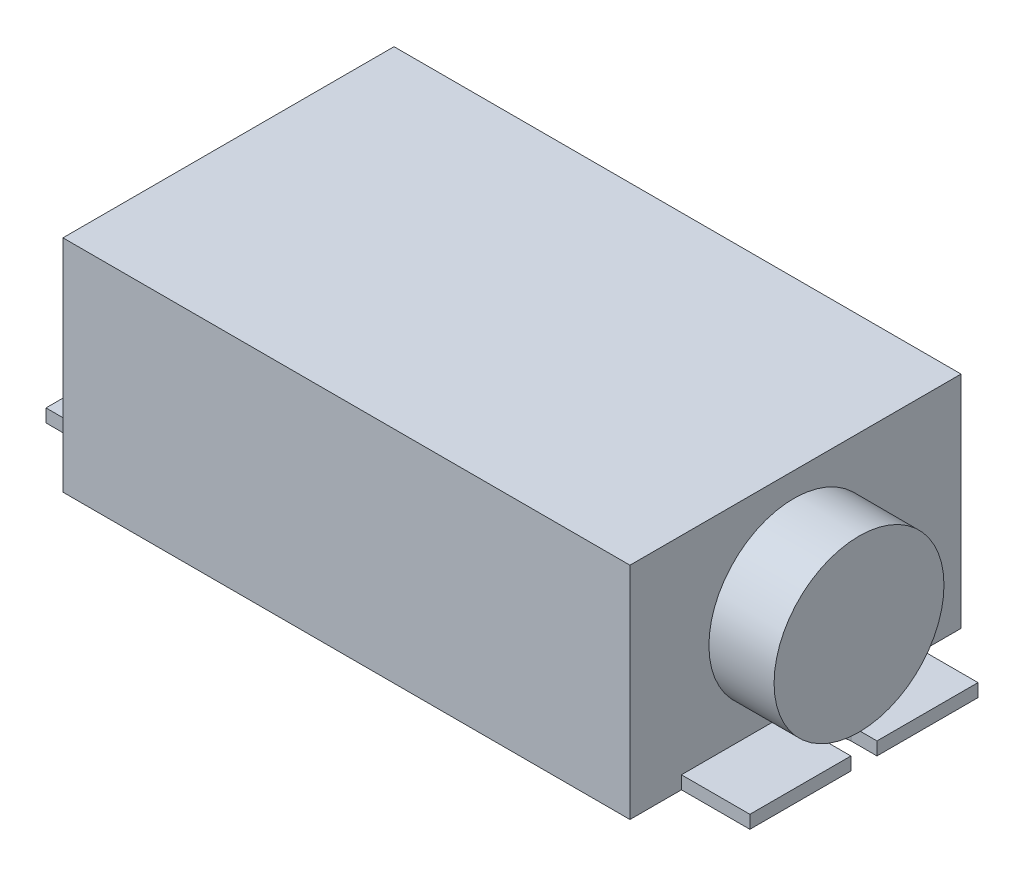
from build123d import *

# Parameters (mm, degrees)
SKETCH1_W           = 87
SKETCH1_H           = 50.8
BOSS_EXTRUDE1_DEPTH = 33.8
BOSS_EXTRUDE2_DEPTH = 2
SKETCH5_R           = 13.034233904
BOSS_EXTRUDE4_DEPTH = 10


with BuildPart() as part:
    # Sketch1 → Boss-Extrude1 (new body)
    with BuildSketch(Plane(origin=(0, 0, 0), x_dir=(1, 0, 0), z_dir=(0, 1, 0))):
        with Locations((43.5, 25.4)):
            Rectangle(SKETCH1_W, SKETCH1_H)
    extrude(amount=BOSS_EXTRUDE1_DEPTH)

    # Sketch2 → Boss-Extrude2 (add)
    with BuildSketch(Plane.XZ):
        with BuildLine():
            Line((0, -42.9), (-10.5, -42.9))
            Line((-10.5, -42.9), (-10.5, -27.4))
            Line((-10.5, -27.4), (-6.5, -27.4))
            ThreePointArc((-6.5, -27.4), (-4.5, -25.4), (-6.5, -23.4))
            Line((-6.5, -23.4), (-10.5, -23.4))
            Line((-10.5, -23.4), (-10.5, -7.9))
            Line((-10.5, -7.9), (0, -7.9))
            Line((0, -7.9), (0, -42.9))
        make_face()
        with BuildLine():
            Line((97.5, -23.4), (97.5, -7.9))
            Line((97.5, -7.9), (87, -7.9))
            Line((87, -7.9), (87, -42.9))
            Line((87, -42.9), (97.5, -42.9))
            Line((97.5, -42.9), (97.5, -27.4))
            Line((97.5, -27.4), (93.5, -27.4))
            ThreePointArc((93.5, -27.4), (91.5, -25.4), (93.5, -23.4))
            Line((93.5, -23.4), (97.5, -23.4))
        make_face()
    extrude(amount=-BOSS_EXTRUDE2_DEPTH)

    # Sketch5 → Boss-Extrude4 (add)
    with BuildSketch(Plane(origin=(87, 0, 0), x_dir=(0, 0, -1), z_dir=(1, 0, 0))):
        with Locations((25.146357233, 17.068762313)):
            Circle(SKETCH5_R)
    extrude(amount=BOSS_EXTRUDE4_DEPTH)


solid = part.part
